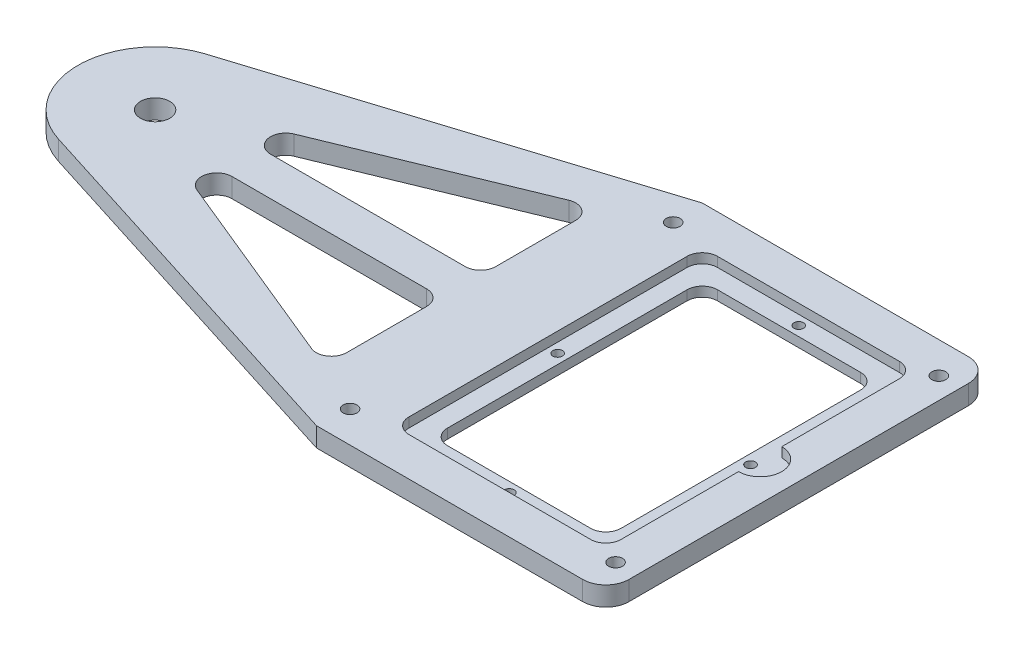
from build123d import *

# Parameters (mm, degrees)
SKETCH1_W           = 95.25
SKETCH1_H           = 127
BOSS_EXTRUDE1_DEPTH = 6.35
BOSS_EXTRUDE3_DEPTH = 6.35
SKETCH5_R           = 4.826
CUT_EXTRUDE1_DEPTH  = 7.35
CUT_EXTRUDE2_DEPTH  = 7.35
FILLET9_R           = 5
SKETCH7_R           = 5.453804141
BOSS_EXTRUDE4_DEPTH = 6.35
SKETCH8_W           = 69.85
SKETCH8_H           = 101.6
CUT_EXTRUDE3_DEPTH  = 3.175
SKETCH9_W           = 57.15
SKETCH9_H           = 88.9
CUT_EXTRUDE4_DEPTH  = 4.175
SKETCH11_R          = 1.5875
CUT_EXTRUDE6_DEPTH  = 4.175
CUT_EXTRUDE7_DEPTH  = 3.175
FILLET10_R          = 5
FILLET11_R          = 5
FILLET12_R          = 7.62
SKETCH13_R          = 2.2812375
CUT_EXTRUDE8_DEPTH  = 7.35


with BuildPart() as part:
    # Sketch1 → Boss-Extrude1 (new body)
    with BuildSketch(Plane(origin=(0, 0, 0), x_dir=(1, 0, 0), z_dir=(0, 1, 0))):
        Rectangle(SKETCH1_W, SKETCH1_H)
    extrude(amount=BOSS_EXTRUDE1_DEPTH)

    # Sketch4 → Boss-Extrude3 (add)
    with BuildSketch(Plane(origin=(0, 6.35, 0), x_dir=(1, 0, 0), z_dir=(0, 1, 0))):
        with BuildLine():
            Line((-47.625, 63.5), (-171.916018217, 24.219268021))
            ThreePointArc((-171.916018217, 24.219268021), (-189.6618, 0), (-171.916018217, -24.219268021))
            Line((-171.916018217, -24.219268021), (-47.625, -63.5))
            Line((-47.625, -63.5), (-47.625, 63.5))
        make_face()
    extrude(amount=-BOSS_EXTRUDE3_DEPTH)

    # Sketch5 → Cut-Extrude1 (cut, through all)
    with BuildSketch(Plane(origin=(0, 6.35, 0), x_dir=(1, 0, 0), z_dir=(0, 1, 0))):
        with Locations((-164.2618, 0)):
            Circle(SKETCH5_R)
        with Locations((-8.6868, 0)):
            Circle(SKETCH5_R)
    extrude(amount=-CUT_EXTRUDE1_DEPTH, mode=Mode.SUBTRACT)

    # Sketch6 → Cut-Extrude2 (cut, through all)
    with BuildSketch(Plane(origin=(0, 6.35, 0), x_dir=(1, 0, 0), z_dir=(0, 1, 0))):
        Polygon((-63.5, 45.163743355), (-157.9118, 6.35), (-63.5, 6.35), align=None)
        Polygon((-63.5, -6.35), (-63.5, -45.163743355), (-157.9118, -6.35), align=None)
    extrude(amount=-CUT_EXTRUDE2_DEPTH, mode=Mode.SUBTRACT)

    # Fillet9
    fillet9_edges = [part.edges().sort_by_distance(p)[0] for p in [
        (-63.5, 3.175, -45.163743355),
        (-63.5, 3.175, -6.35),
        (-157.9118, 3.175, -6.35),
        (-157.9118, 3.175, 6.35),
        (-63.5, 3.175, 6.35),
        (-63.5, 3.175, 45.163743355),
    ]]
    fillet(fillet9_edges, radius=FILLET9_R)

    # Sketch7 → Boss-Extrude4 (add)
    with BuildSketch(Plane(origin=(0, 6.35, 0), x_dir=(1, 0, 0), z_dir=(0, 1, 0))):
        with Locations((-8.6868, 0)):
            Circle(SKETCH7_R)
    extrude(amount=-BOSS_EXTRUDE4_DEPTH)

    # Sketch8 → Cut-Extrude3 (cut)
    with BuildSketch(Plane(origin=(0, 6.35, 0), x_dir=(1, 0, 0), z_dir=(0, 1, 0))):
        Rectangle(SKETCH8_W, SKETCH8_H)
    extrude(amount=-CUT_EXTRUDE3_DEPTH, mode=Mode.SUBTRACT)

    # Sketch9 → Cut-Extrude4 (cut, through all)
    with BuildSketch(Plane(origin=(0, 3.175, 0), x_dir=(1, 0, 0), z_dir=(0, 1, 0))):
        Rectangle(SKETCH9_W, SKETCH9_H)
    extrude(amount=-CUT_EXTRUDE4_DEPTH, mode=Mode.SUBTRACT)

    # Sketch11 → Cut-Extrude6 (cut, through all)
    with BuildSketch(Plane(origin=(0, 3.175, 0), x_dir=(1, 0, 0), z_dir=(0, 1, 0))):
        with Locations((-31.75, 0)):
            Circle(SKETCH11_R)
        with Locations((31.75, 0)):
            Circle(SKETCH11_R)
        with Locations((0, 47.625)):
            Circle(SKETCH11_R)
        with Locations((0, -47.625)):
            Circle(SKETCH11_R)
    extrude(amount=-CUT_EXTRUDE6_DEPTH, mode=Mode.SUBTRACT)

    # Sketch12 → Cut-Extrude7 (cut)
    with BuildSketch(Plane(origin=(0, 6.35, 0), x_dir=(1, 0, 0), z_dir=(0, 1, 0))):
        with BuildLine():
            Line((34.925, 7.112), (34.925, -7.112))
            ThreePointArc((34.925, -7.112), (42.037, 0), (34.925, 7.112))
        make_face()
    extrude(amount=-CUT_EXTRUDE7_DEPTH, mode=Mode.SUBTRACT)

    # Fillet10
    fillet10_edges = [part.edges().sort_by_distance(p)[0] for p in [
        (-34.925, 4.7625, -50.8),
        (34.925, 4.7625, -50.8),
        (34.925, 4.7625, 50.8),
        (-34.925, 4.7625, 50.8),
    ]]
    fillet(fillet10_edges, radius=FILLET10_R)

    # Fillet11
    fillet11_edges = [part.edges().sort_by_distance(p)[0] for p in [
        (-28.575, 1.5875, 44.45),
        (-28.575, 1.5875, -44.45),
        (28.575, 1.5875, -44.45),
        (28.575, 1.5875, 44.45),
    ]]
    fillet(fillet11_edges, radius=FILLET11_R)

    # Fillet12
    fillet12_edges = [part.edges().sort_by_distance(p)[0] for p in [
        (47.625, 3.175, 63.5),
        (47.625, 3.175, -63.5),
    ]]
    fillet(fillet12_edges, radius=FILLET12_R)

    # Sketch13 → Cut-Extrude8 (cut, through all)
    with BuildSketch(Plane(origin=(0, 6.35, 0), x_dir=(1, 0, 0), z_dir=(0, 1, 0))):
        with Locations((-46.889614099, 53.180131976)):
            Circle(SKETCH13_R)
        with Locations((-46.889614099, -53.200246229)):
            Circle(SKETCH13_R)
        with Locations((40.539614099, -53.220360481)):
            Circle(SKETCH13_R)
        with Locations((40.557033552, 53.190189103)):
            Circle(SKETCH13_R)
    extrude(amount=-CUT_EXTRUDE8_DEPTH, mode=Mode.SUBTRACT)


solid = part.part
